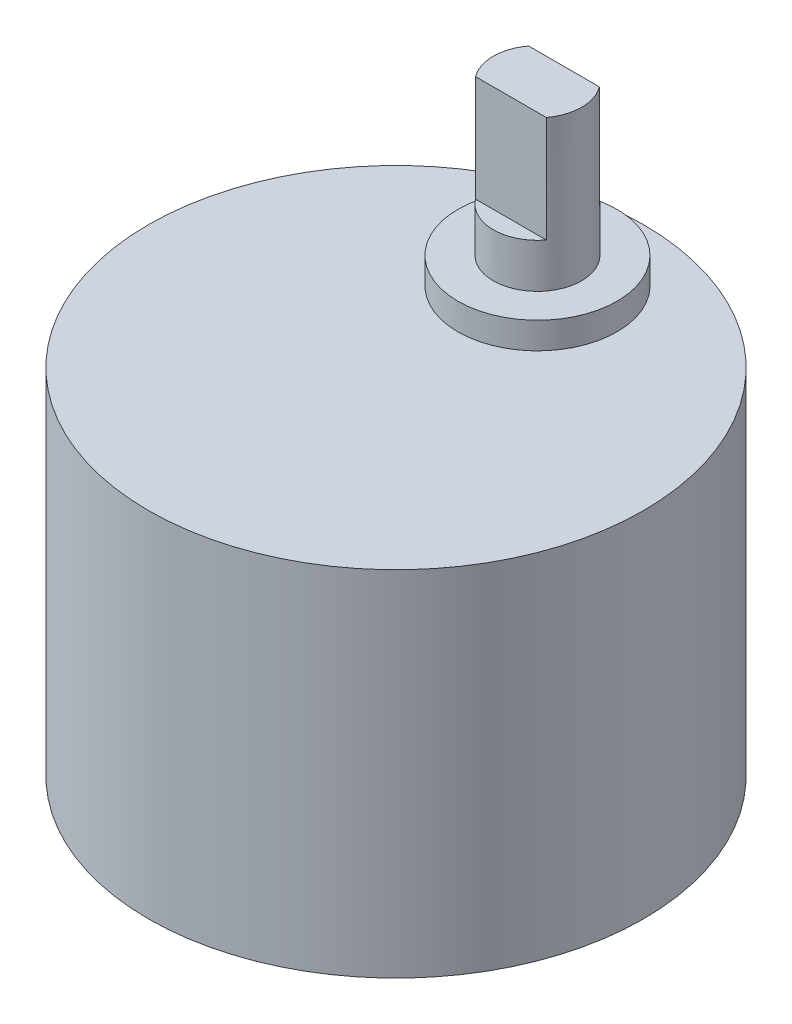
from build123d import *

# Parameters (mm, degrees)
SKETCH1_R           = 14
BOSS_EXTRUDE1_DEPTH = 20
SKETCH3_R           = 4.5
BOSS_EXTRUDE2_DEPTH = 1.5
SKETCH4_R           = 2.5
BOSS_EXTRUDE3_DEPTH = 8.5
CUT_EXTRUDE1_DEPTH  = 6


with BuildPart() as part:
    # Sketch1 → Boss-Extrude1 (new body)
    with BuildSketch(Plane(origin=(0, 0, 0), x_dir=(1, 0, 0), z_dir=(0, 1, 0))):
        Circle(SKETCH1_R)
    extrude(amount=BOSS_EXTRUDE1_DEPTH)

    # Sketch3 → Boss-Extrude2 (add)
    with BuildSketch(Plane(origin=(0, 20, 0), x_dir=(1, 0, 0), z_dir=(0, 1, 0))):
        with Locations((0, 8)):
            Circle(SKETCH3_R)
    extrude(amount=BOSS_EXTRUDE2_DEPTH)

    # Sketch4 → Boss-Extrude3 (add)
    with BuildSketch(Plane(origin=(0, 21.5, 0), x_dir=(1, 0, 0), z_dir=(0, 1, 0))):
        with Locations((0, 8)):
            Circle(SKETCH4_R)
    extrude(amount=BOSS_EXTRUDE3_DEPTH)

    # Sketch5 → Cut-Extrude1 (cut)
    with BuildSketch(Plane(origin=(0, 30, 0), x_dir=(1, 0, 0), z_dir=(0, 1, 0))):
        with BuildLine():
            Line((2, 9.5), (-2, 9.5))
            ThreePointArc((-2, 9.5), (0, 10.5), (2, 9.5))
        make_face()
        with BuildLine():
            Line((-2, 6.5), (2, 6.5))
            ThreePointArc((2, 6.5), (0, 5.5), (-2, 6.5))
        make_face()
    extrude(amount=-CUT_EXTRUDE1_DEPTH, mode=Mode.SUBTRACT)


solid = part.part
